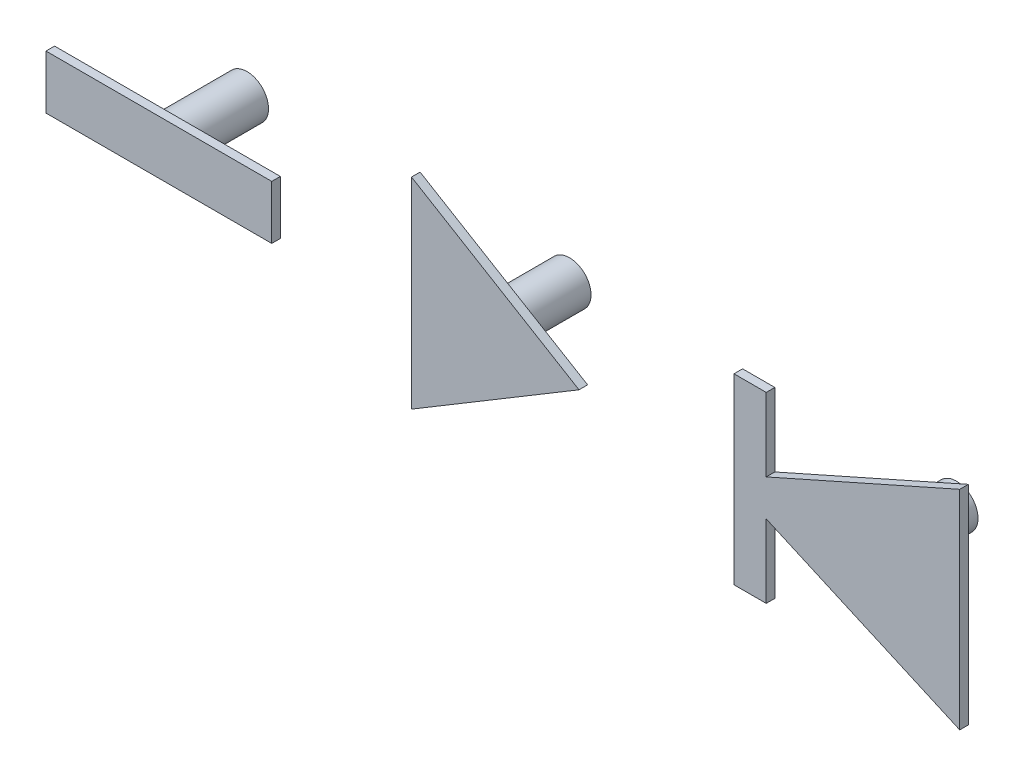
from build123d import *

# Parameters (mm, degrees)
BOSS_EXTRUDE3_DEPTH        = 0.1
BOSS_EXTRUDE3_DEPTH_BACK   = 0.3
BOSS_EXTRUDE3_2_DEPTH      = 0.1
BOSS_EXTRUDE3_2_DEPTH_BACK = 0.3
SKETCH5_W                  = 10.5
SKETCH5_H                  = 2.5
BOSS_EXTRUDE3_3_DEPTH      = 0.1
BOSS_EXTRUDE3_3_DEPTH_BACK = 0.3
SKETCH6_R                  = 1
BOSS_EXTRUDE4_DEPTH        = 4


with BuildPart() as part:
    # Sketch5 → Boss-Extrude3 (new body, two sides)
    with BuildSketch(Plane.XY.offset(5)) as boss_extrude3_sk:
        Polygon((-4.25, 4.675357216), (-4.25, -4.675357216), (3.542262026, 0), align=None)
    extrude(amount=BOSS_EXTRUDE3_DEPTH)
    extrude(boss_extrude3_sk.sketch, amount=-BOSS_EXTRUDE3_DEPTH_BACK)



with BuildPart() as body_2:
    # Sketch5 → Boss-Extrude3 2 (new body, two sides)
    with BuildSketch(Plane.XY.offset(5)) as boss_extrude3_2_sk:
        Polygon((10.75, 4.25), (10.75, -4.25), (12.25, -4.25), (12.25, -0.845928517), (21.25, -4.845928517), (21.25, 4.845928517), (12.25, 0.845928517), (12.25, 4.25), align=None)
    extrude(amount=BOSS_EXTRUDE3_2_DEPTH)
    extrude(boss_extrude3_2_sk.sketch, amount=-BOSS_EXTRUDE3_2_DEPTH_BACK)


with BuildPart() as body_3:
    # Sketch5 → Boss-Extrude3 3 (new body, two sides)
    with BuildSketch(Plane.XY.offset(5)) as boss_extrude3_3_sk:
        with Locations((-16, 0)):
            Rectangle(SKETCH5_W, SKETCH5_H)
    extrude(amount=BOSS_EXTRUDE3_3_DEPTH)
    extrude(boss_extrude3_3_sk.sketch, amount=-BOSS_EXTRUDE3_3_DEPTH_BACK)


with BuildPart() as part_1:
    add(part.part)

    add(body_2.part)  # Boss-Extrude4 merges body 2

    add(body_3.part)  # Boss-Extrude4 merges body 3
    # Sketch6 → Boss-Extrude4 (add)
    with BuildSketch(Plane.XY.offset(5)):
        with Locations((-16, 0)):
            Circle(SKETCH6_R)
        with Locations((-1, 0)):
            Circle(SKETCH6_R)
        with Locations((17, 0)):
            Circle(SKETCH6_R)
    extrude(amount=-BOSS_EXTRUDE4_DEPTH)


solid = part_1.part
